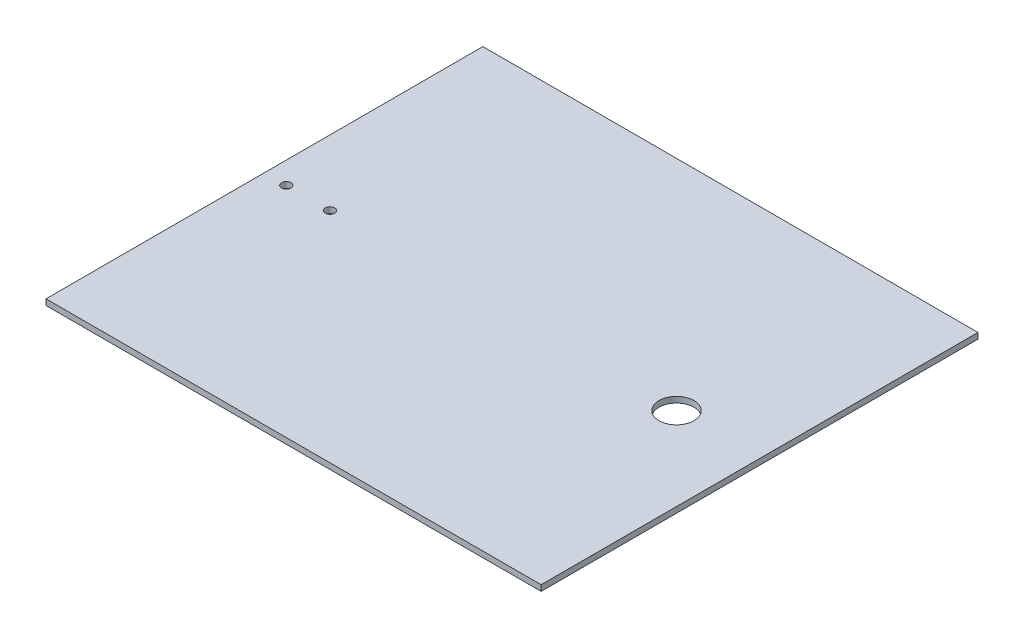
from build123d import *

# Parameters (mm, degrees)
BOSS_EXTRUDE3_DEPTH = 150
SKETCH4_R           = 1.6
CUT_EXTRUDE1_DEPTH  = 10
SKETCH5_R           = 6
CUT_EXTRUDE2_DEPTH  = 10


with BuildPart() as part:
    # Sketch3 → Boss-Extrude3 (new body)
    with BuildSketch(Plane.XY):
        Polygon((0, 0), (85, 0), (85, -2), (0, -2), (-85, -2), (-85, 0), align=None)
    extrude(amount=BOSS_EXTRUDE3_DEPTH)

    # Sketch4 → Cut-Extrude1 (cut)
    with BuildSketch(Plane(origin=(0, 0, 0), x_dir=(1, 0, 0), z_dir=(0, 1, 0))):
        with Locations((-77.5, -75)):
            Circle(SKETCH4_R)
        with Locations((-62.5, -75)):
            Circle(SKETCH4_R)
    extrude(amount=-CUT_EXTRUDE1_DEPTH, mode=Mode.SUBTRACT)

    # Sketch5 → Cut-Extrude2 (cut)
    with BuildSketch(Plane(origin=(0, 0, 0), x_dir=(1, 0, 0), z_dir=(0, 1, 0))):
        with Locations((56.485157875, -75)):
            Circle(SKETCH5_R)
    extrude(amount=-CUT_EXTRUDE2_DEPTH, mode=Mode.SUBTRACT)


solid = part.part
